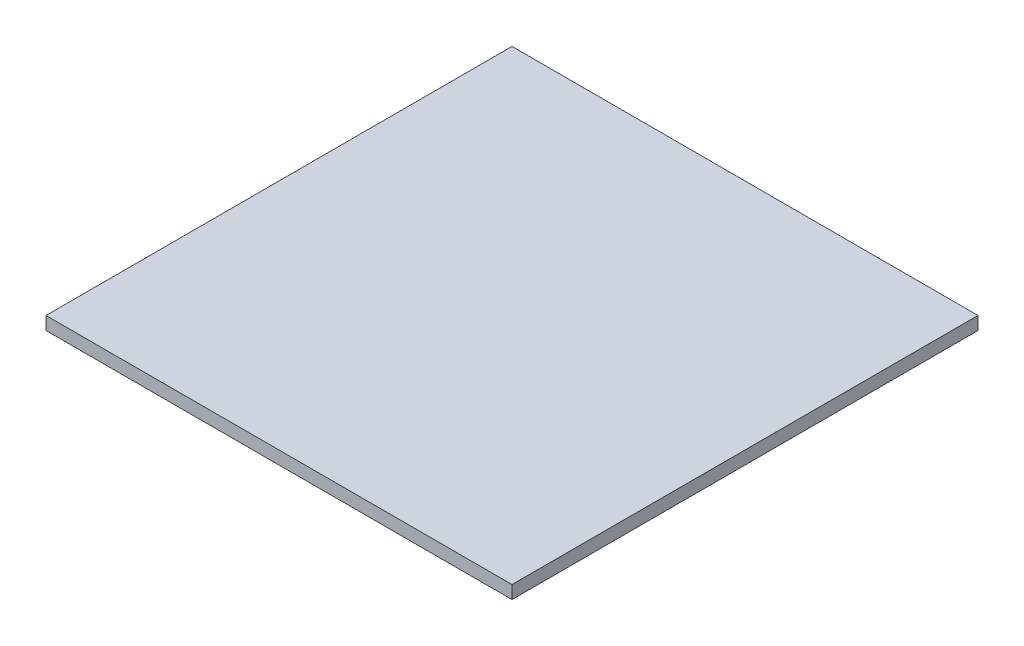
from build123d import *

# Parameters (mm, degrees)
SKETCH1_W           = 25
SKETCH1_H           = 25
BOSS_EXTRUDE1_DEPTH = 0.35


with BuildPart() as part:
    # Sketch1 → Boss-Extrude1 (new body, symmetric)
    with BuildSketch(Plane(origin=(0, 0, 0), x_dir=(1, 0, 0), z_dir=(0, 1, 0))):
        Rectangle(SKETCH1_W, SKETCH1_H)
    extrude(amount=BOSS_EXTRUDE1_DEPTH, both=True)


solid = part.part
